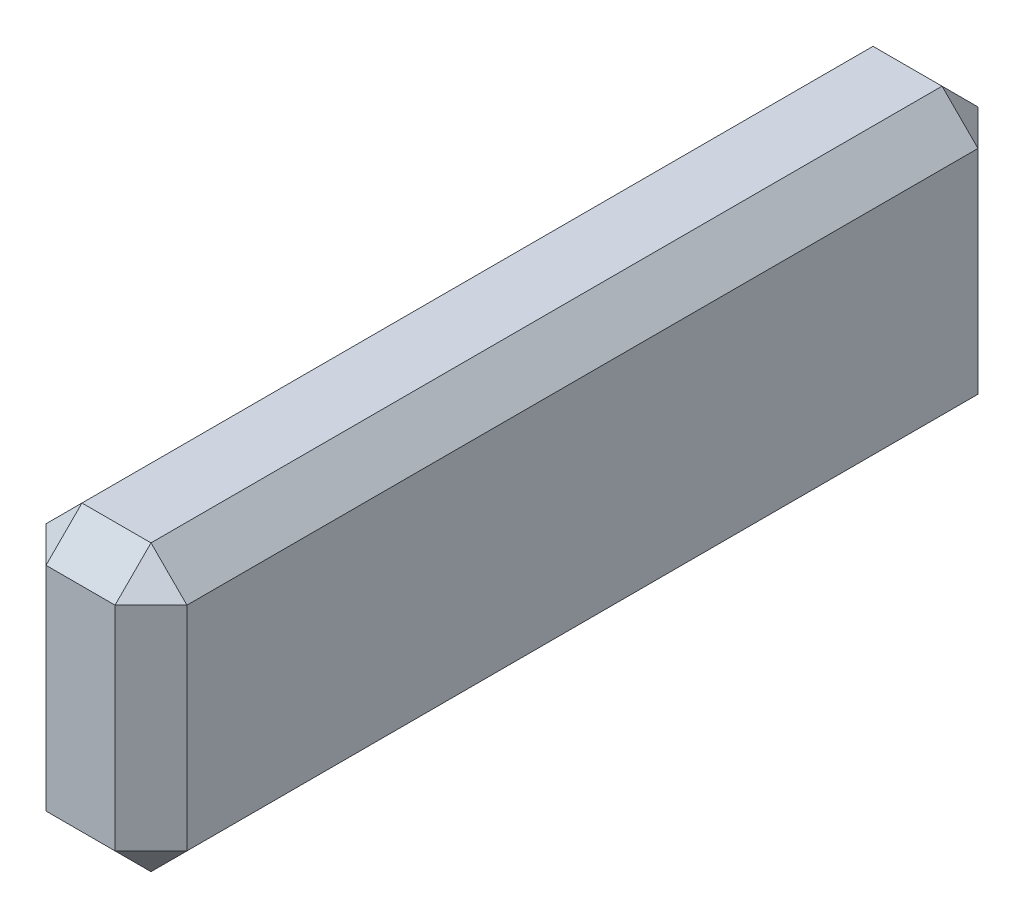
from build123d import *

# Parameters (mm, degrees)
SKETCH5_W           = 6.223
SKETCH5_H           = 12.573
BOSS_EXTRUDE3_DEPTH = 38.1
CHAMFER1_SIZE       = 1.5875


with BuildPart() as part:
    # Sketch5 → Boss-Extrude3 (new body)
    with BuildSketch(Plane.XY):
        Rectangle(SKETCH5_W, SKETCH5_H)
    extrude(amount=BOSS_EXTRUDE3_DEPTH)

    # Chamfer1
    chamfer1_edges = [part.edges().sort_by_distance(p)[0] for p in [
        (-3.1115, 0, 38.1),
        (0, -6.2865, 38.1),
        (3.1115, 0, 38.1),
        (0, -6.2865, 0),
        (-3.1115, 0, 0),
        (0, 6.2865, 0),
        (3.1115, 0, 0),
        (0, 6.2865, 38.1),
        (3.1115, -6.2865, 19.05),
        (-3.1115, -6.2865, 19.05),
        (-3.1115, 6.2865, 19.05),
        (3.1115, 6.2865, 19.05),
    ]]
    chamfer(chamfer1_edges, length=CHAMFER1_SIZE)


solid = part.part
